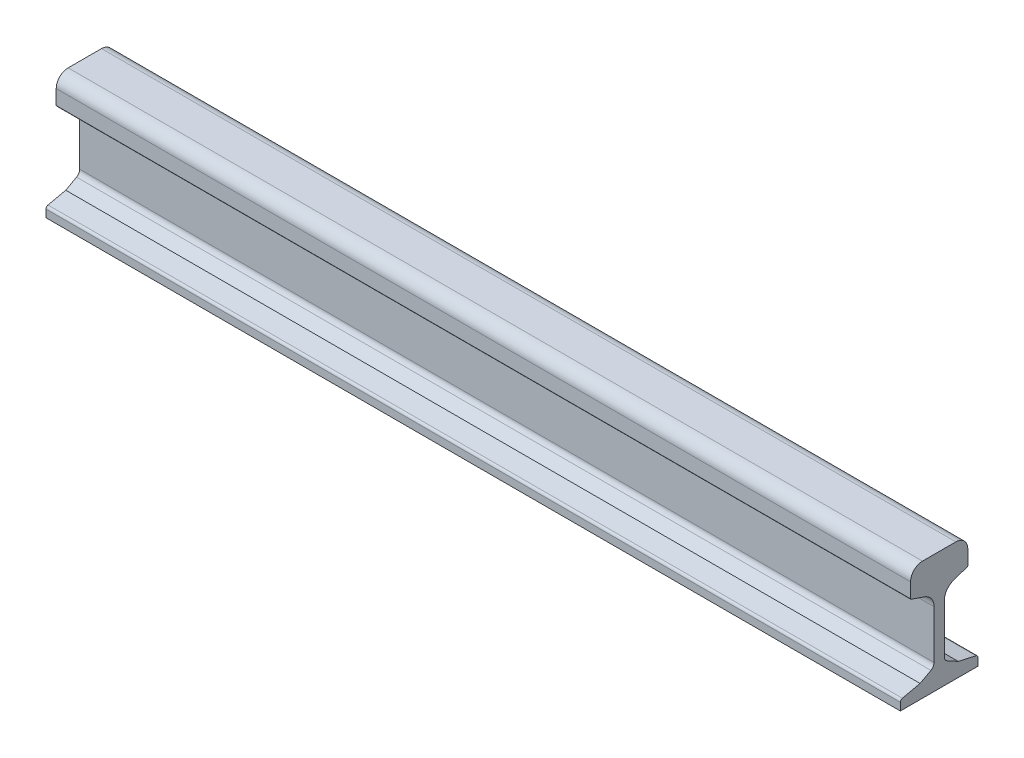
from build123d import *

# Parameters (mm, degrees)
AUFSATZ_LINEAR_AUSTRAGEN1_DEPTH = 500


with BuildPart() as part:
    # Skizze1 → Aufsatz-Linear austragen1 (new body, symmetric)
    with BuildSketch(Plane(origin=(0, 0, 0), x_dir=(0, 0, -1), z_dir=(1, 0, 0))):
        with BuildLine():
            Line((-45.456738262, -1.013535579), (45.456738262, -1.013535579))
            Line((45.456738262, -1.013535579), (45.456738262, 7.828778751))
            ThreePointArc((45.456738262, 7.828778751), (44.798122061, 9.704391159), (43.111456992, 10.756464421))
            Line((43.111456992, 10.756464421), (22.36480763, 15.396040337))
            Line((22.36480763, 15.396040337), (9.658162352, 22.299803874))
            ThreePointArc((9.658162352, 22.299803874), (6.983652955, 24.872378626), (6, 28.45058603))
            Line((6, 28.45058603), (6, 85.036336881))
            ThreePointArc((6, 85.036336881), (9.227773203, 94.794679734), (17.637809302, 100.703577084))
            Line((17.637809302, 100.703577084), (32.825814996, 105.937662587))
            ThreePointArc((32.825814996, 105.937662587), (33.314191315, 106.302499454), (33.5, 106.883096132))
            Line((33.5, 106.883096132), (33.5, 124))
            ThreePointArc((33.5, 124), (29.399494937, 133.899494937), (19.5, 138))
            Line((19.5, 138), (-19.5, 138))
            ThreePointArc((-19.5, 138), (-29.399494937, 133.899494937), (-33.5, 124))
            Line((-33.5, 124), (-33.5, 106.883096132))
            ThreePointArc((-33.5, 106.883096132), (-33.314191315, 106.302499454), (-32.825814996, 105.937662587))
            Line((-32.825814996, 105.937662587), (-17.637809302, 100.703577084))
            ThreePointArc((-17.637809302, 100.703577084), (-9.227773203, 94.794679734), (-6, 85.036336881))
            Line((-6, 85.036336881), (-6, 28.45058603))
            ThreePointArc((-6, 28.45058603), (-6.983652955, 24.872378626), (-9.658162352, 22.299803874))
            Line((-9.658162352, 22.299803874), (-22.36480763, 15.396040337))
            Line((-22.36480763, 15.396040337), (-43.111456992, 10.756464421))
            ThreePointArc((-43.111456992, 10.756464421), (-44.798122061, 9.704391159), (-45.456738262, 7.828778751))
            Line((-45.456738262, 7.828778751), (-45.456738262, -1.013535579))
        make_face()
    extrude(amount=AUFSATZ_LINEAR_AUSTRAGEN1_DEPTH, both=True)


solid = part.part
